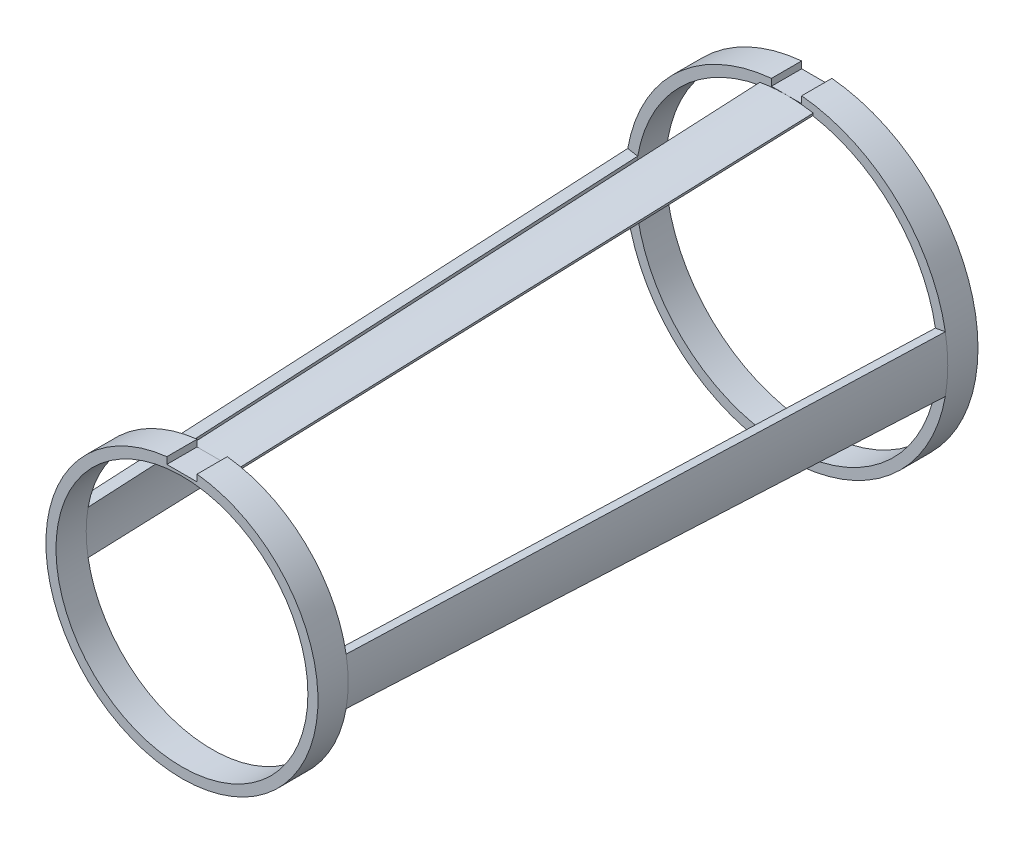
from build123d import *

# Parameters (mm, degrees)
SKETCH1_R                      = 40.64
SKETCH1_R_2                    = 38.1
BOSS_EXTRUDE1_DEPTH            = 3.81
CUT_EXTRUDE1_REACH             = 5.81
SKETCH2_W                      = 7.62
SKETCH2_H                      = 3.81
CUT_EXTRUDE1_DIRECTION_2_REACH = 5.81
SKETCH3_R                      = 34.29
SKETCH3_R_2                    = 31.75
BOSS_EXTRUDE2_DEPTH            = 3.81
REVOLVE1_ANGLE                 = 10
REVOLVE1_OTHER_WAY_ANGLE       = 10
CUT_EXTRUDE2_REACH             = 162.02
SKETCH6_W                      = 7.62
SKETCH6_H                      = 3.81
REVOLVE2_ANGLE                 = 10
REVOLVE2_OTHER_WAY_ANGLE       = 10


with BuildPart() as part:
    # Sketch1 → Boss-Extrude1 (new body, symmetric)
    with BuildSketch(Plane.XY):
        Circle(SKETCH1_R)
        Circle(SKETCH1_R_2, mode=Mode.SUBTRACT)
    extrude(amount=BOSS_EXTRUDE1_DEPTH, both=True)

    # Sketch2 → Cut-Extrude1 (cut, up to next)
    with BuildSketch(Plane.XY, mode=Mode.PRIVATE) as cut_extrude1_sk1:
        with Locations((0, 40.64)):
            Rectangle(SKETCH2_W, SKETCH2_H)
    cut_extrude1_tool1 = extrude(cut_extrude1_sk1.sketch, amount=-CUT_EXTRUDE1_REACH, mode=Mode.PRIVATE) & part.part
    add(cut_extrude1_tool1.solids().sort_by_distance((0, 40.64, 0))[0], mode=Mode.SUBTRACT)

    # Sketch2 → Cut-Extrude1 direction 2 (cut, up to next)
    with BuildSketch(Plane.XY, mode=Mode.PRIVATE) as cut_extrude1_direction_2_sk1:
        with Locations((0, 40.64)):
            Rectangle(SKETCH2_W, SKETCH2_H)
    cut_extrude1_direction_2_tool1 = extrude(cut_extrude1_direction_2_sk1.sketch, amount=CUT_EXTRUDE1_DIRECTION_2_REACH, mode=Mode.PRIVATE) & part.part
    add(cut_extrude1_direction_2_tool1.solids().sort_by_distance((0, 40.64, 0))[0], mode=Mode.SUBTRACT)



with BuildPart() as body_2:
    # Sketch3 → Boss-Extrude2 (new body, symmetric)
    with BuildSketch(Plane.XY.offset(152.4)):
        Circle(SKETCH3_R)
        Circle(SKETCH3_R_2, mode=Mode.SUBTRACT)
    extrude(amount=BOSS_EXTRUDE2_DEPTH, both=True)


with BuildPart() as part_1:
    add(part.part)

    add(body_2.part)  # Revolve1 merges body 2
    # Sketch5 → Revolve1 (revolve)
    with BuildSketch(Plane(origin=(0, 0, 0), x_dir=(1, 0, 0), z_dir=(0, 1, 0))):
        Polygon((-40.64, -3.81), (-34.29, -148.59), (-31.75, -148.59), (-38.1, -3.81), align=None)
        Polygon((40.64, -3.81), (34.29, -148.59), (31.75, -148.59), (38.1, -3.81), align=None)
    revolve(axis=Axis((0, 0, -17.154345007), (0, 0, 1)), revolution_arc=REVOLVE1_ANGLE)

    # Sketch5 → Revolve1 other way (revolve)
    with BuildSketch(Plane(origin=(0, 0, 0), x_dir=(1, 0, 0), z_dir=(0, 1, 0))):
        Polygon((-40.64, -3.81), (-34.29, -148.59), (-31.75, -148.59), (-38.1, -3.81), align=None)
        Polygon((40.64, -3.81), (34.29, -148.59), (31.75, -148.59), (38.1, -3.81), align=None)
    revolve(axis=Axis((0, 0, -17.154345007), (0, 0, -1)), revolution_arc=REVOLVE1_OTHER_WAY_ANGLE)

    # Sketch6 → Cut-Extrude2 (cut, up to next)
    with BuildSketch(Plane.XY.offset(156.21), mode=Mode.PRIVATE) as cut_extrude2_sk1:
        with Locations((0, 34.29)):
            Rectangle(SKETCH6_W, SKETCH6_H)
    cut_extrude2_tool1 = extrude(cut_extrude2_sk1.sketch, amount=-CUT_EXTRUDE2_REACH, mode=Mode.PRIVATE) & part_1.part
    add(cut_extrude2_tool1.solids().sort_by_distance((0, 34.29, 156.21))[0], mode=Mode.SUBTRACT)

    # Sketch11 → Revolve2 (revolve)
    with BuildSketch(Plane(origin=(0, 0, 0), x_dir=(0, 0, -1), z_dir=(1, 0, 0))):
        Polygon((-148.59, 32.385), (-3.81, 38.735), (-3.81, 38.1), (-148.59, 31.75), align=None)
    revolve(axis=Axis((0, 0, 0), (0, 0, 1)), revolution_arc=REVOLVE2_ANGLE)

    # Sketch11 → Revolve2 other way (revolve)
    with BuildSketch(Plane(origin=(0, 0, 0), x_dir=(0, 0, -1), z_dir=(1, 0, 0))):
        Polygon((-148.59, 32.385), (-3.81, 38.735), (-3.81, 38.1), (-148.59, 31.75), align=None)
    revolve(axis=Axis((0, 0, 0), (0, 0, -1)), revolution_arc=REVOLVE2_OTHER_WAY_ANGLE)


solid = part_1.part
